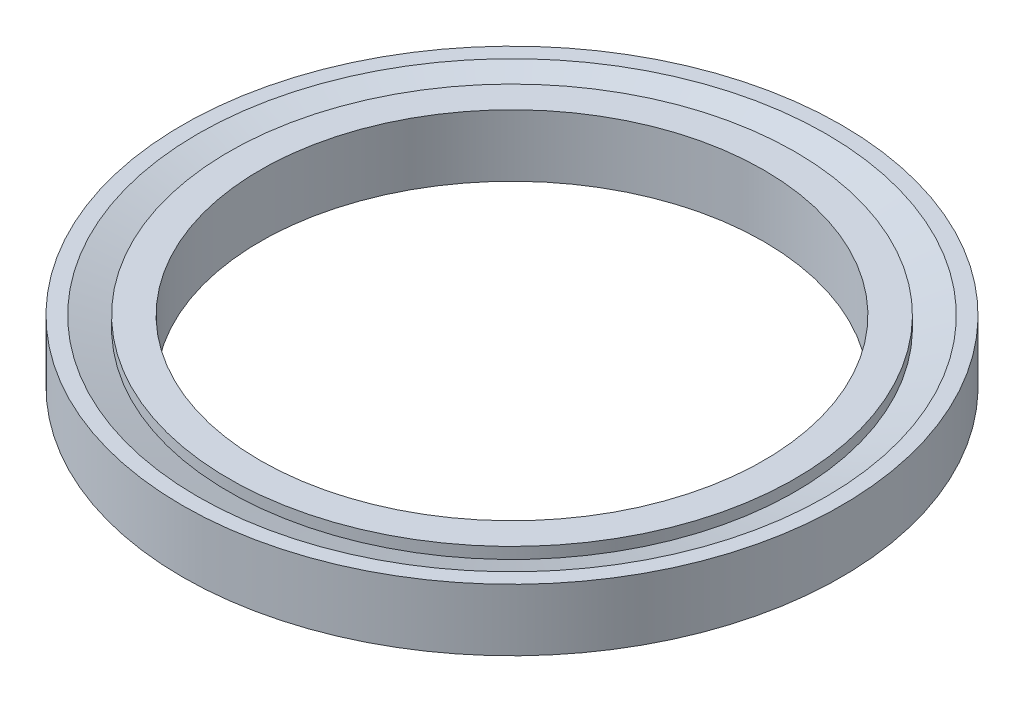
from build123d import *

# Parameters (mm, degrees)
SKETCH1_W          = 10.6426
SKETCH1_H          = 1.999996
SKETCH3_R          = 8.128
CUT_EXTRUDE1_DEPTH = 2.999996


with BuildPart() as part:
    # Sketch1 → Revolve1 (revolve)
    with BuildSketch(Plane.XY):
        with Locations((5.3213, 0)):
            Rectangle(SKETCH1_W, SKETCH1_H)
    revolve(axis=Axis((0, 0.999998, 0), (0, -1, 0)))

    # Sketch2 → Cut-Revolve1 (revolve, cut)
    with BuildSketch(Plane.XY):
        Polygon((-9.144, 0.635), (-9.144, 1.217425169), (-10.7442, 1.217425169), align=None)
        Polygon((-10.7442, -1.217425169), (-9.144, -0.635), (-9.144, -1.217425169), align=None)
    revolve(axis=Axis((0, 0, 0), (0, 1, 0)), mode=Mode.SUBTRACT)

    # Sketch3 → Cut-Extrude1 (cut, through all)
    with BuildSketch(Plane(origin=(0, 0.999998, 0), x_dir=(1, 0, 0), z_dir=(0, 1, 0))):
        Circle(SKETCH3_R)
    extrude(amount=-CUT_EXTRUDE1_DEPTH, mode=Mode.SUBTRACT)


solid = part.part
